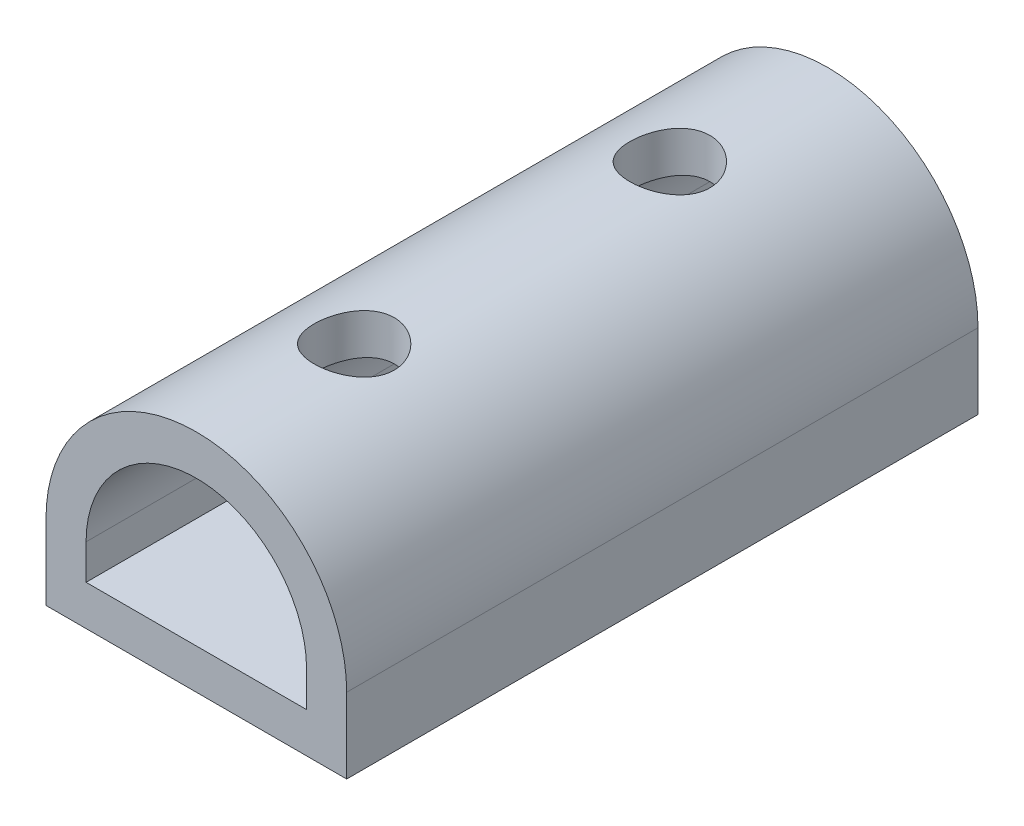
from build123d import *

# Parameters (mm, degrees)
BOSS_EXTRUDE1_DEPTH = 20
CUT_EXTRUDE1_START  = -7.14375
SKETCH2_R           = 1.27
CUT_EXTRUDE1_DEPTH  = 7.14375


with BuildPart() as part:
    # Sketch1 → Boss-Extrude1 (new body)
    with BuildSketch(Plane.XY):
        with BuildLine():
            Line((-4.7625, -2.38125), (4.7625, -2.38125))
            Line((4.7625, -2.38125), (4.7625, 0))
            ThreePointArc((4.7625, 0), (0, 4.7625), (-4.7625, 0))
            Line((-4.7625, 0), (-4.7625, -2.38125))
        make_face()
        with BuildLine():
            Line((-3.4925, -1.11125), (3.4925, -1.11125))
            Line((3.4925, -1.11125), (3.4925, 0))
            ThreePointArc((3.4925, 0), (0, 3.4925), (-3.4925, 0))
            Line((-3.4925, 0), (-3.4925, -1.11125))
        make_face(mode=Mode.SUBTRACT)
    extrude(amount=BOSS_EXTRUDE1_DEPTH)

    # Sketch2 → Cut-Extrude1 (cut)
    with BuildSketch(Plane(origin=(0, -2.38125, 0), x_dir=(-1, 0, 0), z_dir=(0, -1, 0)).offset(CUT_EXTRUDE1_START)):
        with Locations((0, -15.000000033)):
            Circle(SKETCH2_R)
        with Locations((0, -4.999999967)):
            Circle(SKETCH2_R)
    extrude(amount=CUT_EXTRUDE1_DEPTH, mode=Mode.SUBTRACT)


solid = part.part
